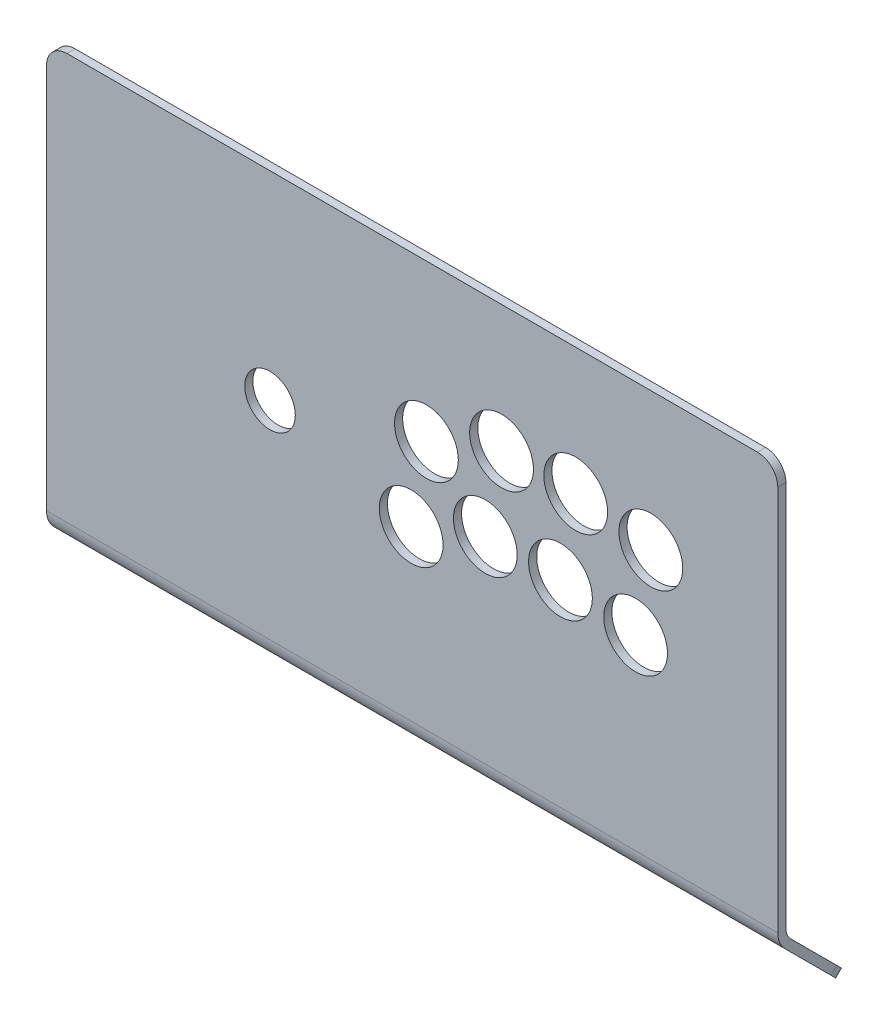
from build123d import *

# Parameters (mm, degrees)
SALIENTE_EXTRUIR1_DEPTH = 180
CROQUIS3_R              = 12.450594948
CROQUIS3_R_2            = 15.7
CORTAR_EXTRUIR1_DEPTH   = 37.14486815
REDONDEO1_R             = 10


with BuildPart() as part:
    # Croquis1 → Saliente-Extruir1 (new body, symmetric)
    with BuildSketch(Plane(origin=(0, 0, 0), x_dir=(0, 0, -1), z_dir=(1, 0, 0))):
        with BuildLine():
            Line((-2, 0), (-2, -200))
            ThreePointArc((-2, -200), (-1.08655439, -204.592201188), (1.514718626, -208.485281374))
            Line((1.514718626, -208.485281374), (31.316441026, -238.287003774))
            Line((31.316441026, -238.287003774), (34.14486815, -235.458576649))
            Line((34.14486815, -235.458576649), (4.343145751, -205.656854249))
            ThreePointArc((4.343145751, -205.656854249), (2.60896374, -203.061467459), (2, -200))
            Line((2, -200), (2, 0))
            Line((2, 0), (-2, 0))
        make_face()
    extrude(amount=SALIENTE_EXTRUIR1_DEPTH, both=True)

    # Croquis3 → Cortar-Extruir1 (cut, through all)
    with BuildSketch(Plane.XY.offset(2)):
        with Locations((-70, -98)):
            Circle(CROQUIS3_R)
        with Locations((7, -77)):
            Circle(CROQUIS3_R_2)
        with Locations((-0.5, -117)):
            Circle(CROQUIS3_R_2)
        with Locations((36, -103)):
            Circle(CROQUIS3_R_2)
        with Locations((73, -103)):
            Circle(CROQUIS3_R_2)
        with Locations((110, -108)):
            Circle(CROQUIS3_R_2)
        with Locations((117.5, -68)):
            Circle(CROQUIS3_R_2)
        with Locations((80.5, -62.5)):
            Circle(CROQUIS3_R_2)
        with Locations((44, -62.5)):
            Circle(CROQUIS3_R_2)
    extrude(amount=-CORTAR_EXTRUIR1_DEPTH, mode=Mode.SUBTRACT)

    # Redondeo1
    redondeo1_edges = [part.edges().sort_by_distance(p)[0] for p in [
        (-180, 0, 0),
        (180, -236.872790212, -32.730654588),
        (180, 0, 0),
        (-180, -236.872790212, -32.730654588),
    ]]
    fillet(redondeo1_edges, radius=REDONDEO1_R)


solid = part.part
